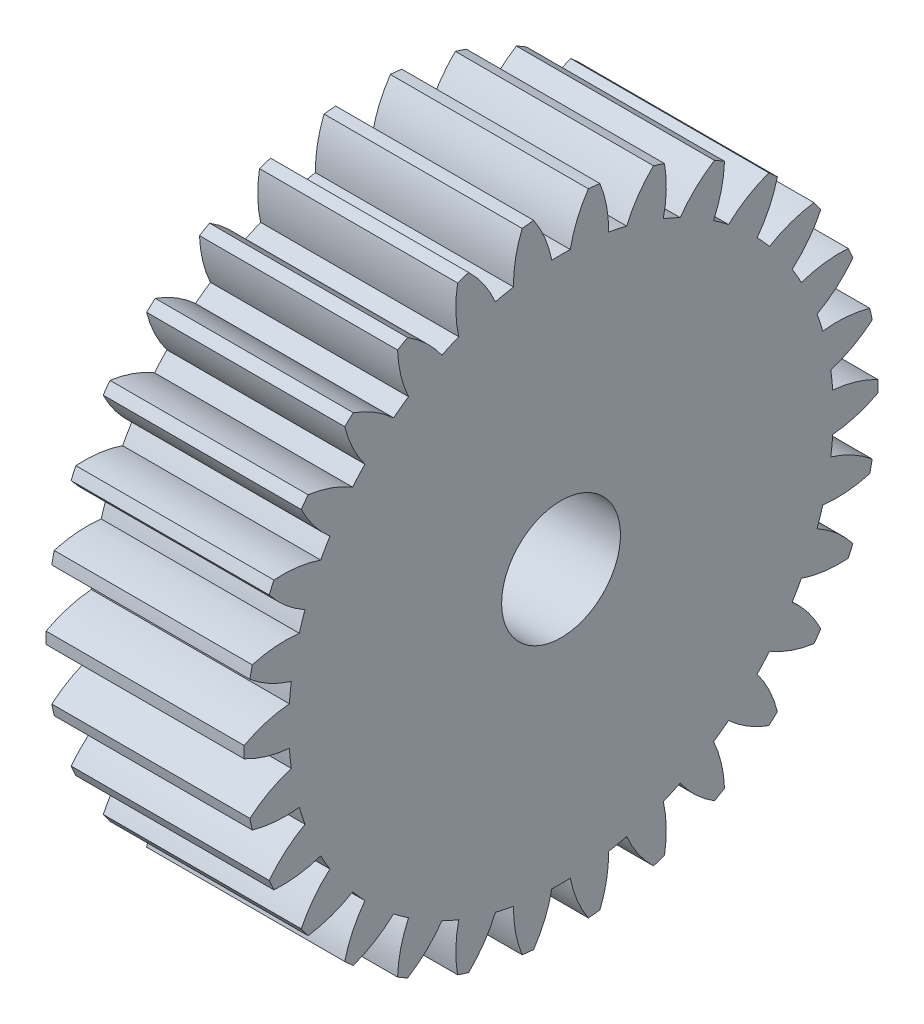
from build123d import *

# Parameters (mm, degrees)
BASPROSKE_W     = 10
BASPROSKE_H     = 16
TOOTHCUT_DEPTH  = 25.738633754
TEETHCUTS_COUNT = 30
TEETHCUTS_ANGLE = 348
BORSKE_R        = 3
BORE_DEPTH      = 50.0000508


with BuildPart() as part:
    # BasProSke → Base-Revolve (revolve)
    with BuildSketch(Plane(origin=(0, 0, 0), x_dir=(1, 0, 0), z_dir=(0, 1, 0)), mode=Mode.PRIVATE) as base_revolve_sk:
        with Locations((5, 8)):
            Rectangle(BASPROSKE_W, BASPROSKE_H)
    revolve(base_revolve_sk.sketch.rotate(Axis((-10, 0, 0), (1, 0, 0)), 180), axis=Axis((-10, 0, 0), (1, 0, 0)))

    # TooCutSke → ToothCut (cut, through all)
    with BuildSketch(Plane(origin=(0, 0, 0), x_dir=(0, 0, -1), z_dir=(1, 0, 0))):
        with BuildLine():
            ThreePointArc((0.466400716, 13.741086979), (0, 13.749), (-0.466400716, 13.741086979))
            ThreePointArc((-0.466400716, 13.741086979), (-0.819142092, 14.899954875), (-1.3974676, 15.964351834))
            ThreePointArc((-1.3974676, 15.964351834), (0, 16.0254), (1.3974676, 15.964351834))
            ThreePointArc((1.3974676, 15.964351834), (0.819142092, 14.899954875), (0.466400716, 13.741086979))
        make_face()
    toothcut = extrude(amount=TOOTHCUT_DEPTH, mode=Mode.SUBTRACT)

    # TeethCuts: ToothCut ×30 about axis
    teethcuts_axis = Axis((-10, 0, 0), (1, 0, 0))
    for i in range(1, TEETHCUTS_COUNT):
        add(toothcut.rotate(teethcuts_axis, i * TEETHCUTS_ANGLE / (TEETHCUTS_COUNT - 1)), mode=Mode.SUBTRACT)

    # BorSke → Bore (cut, symmetric)
    with BuildSketch(Plane(origin=(0, 0, 0), x_dir=(0, 0, -1), z_dir=(1, 0, 0))):
        with Locations(Location((0, 0, 0), (0, 0, 180))):
            Circle(BORSKE_R)
    extrude(amount=BORE_DEPTH, both=True, mode=Mode.SUBTRACT)


solid = part.part
